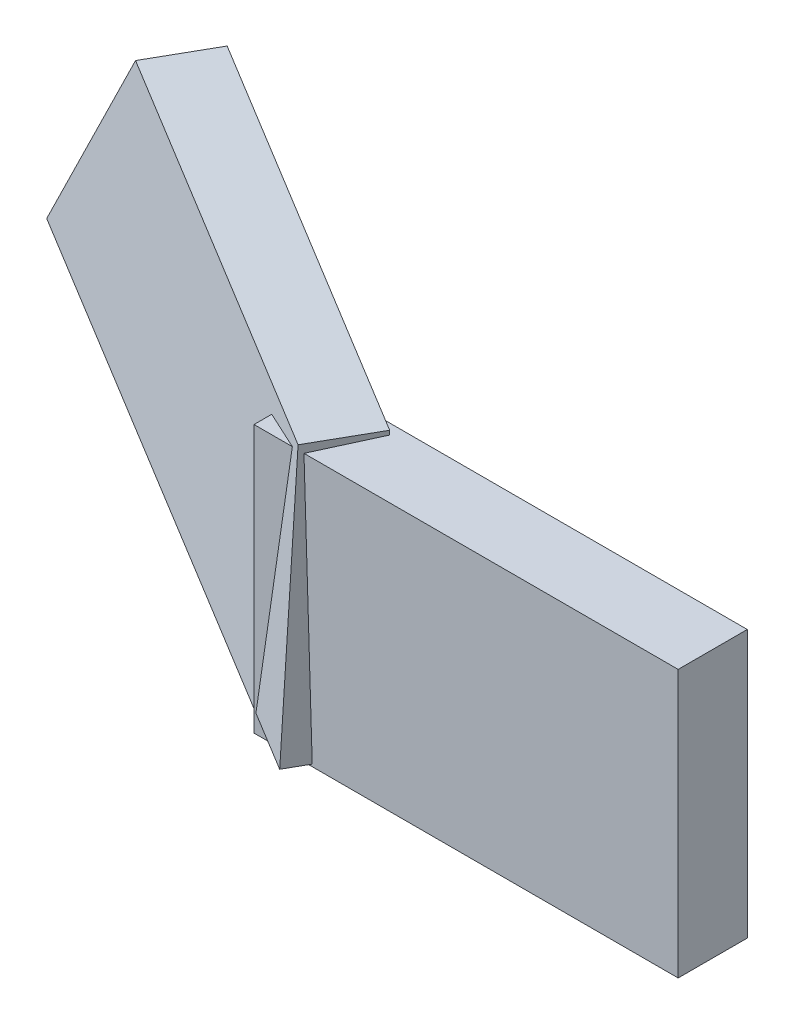
from build123d import *

# Parameters (mm, degrees)
SKETCH1_W           = 61.345012487
SKETCH1_H           = 38.657423861
BOSS_EXTRUDE1_DEPTH = 10
BOSS_EXTRUDE2_DEPTH = 10
SKETCH3_W           = 55.653219253
SKETCH3_H           = 4.667772156
BOSS_EXTRUDE3_DEPTH = 3
BOSS_EXTRUDE4_DEPTH = 3


with BuildPart() as part:
    # Sketch1 → Boss-Extrude1 (new body)
    with BuildSketch(Plane.XY):
        with Locations((-23.425520154, 10.330558338)):
            Rectangle(SKETCH1_W, SKETCH1_H)
    extrude(amount=BOSS_EXTRUDE1_DEPTH)

    # Sketch2 → Boss-Extrude2 (add)
    with BuildSketch(Plane(origin=(-8.887322321, 1.300253896, 19.221447103), x_dir=(0.908038086, 0.028271458, 0.417932481), z_dir=(-0.418887615, 0.061285079, 0.905967607))):
        Polygon((-87.68448092, 45.888055238), (-37.545380932, 30.082102221), (-37.545380932, -9.327101998), (-109.421725422, 13.33134469), align=None)
    extrude(amount=BOSS_EXTRUDE2_DEPTH)

    # Sketch3 → Boss-Extrude3 (add)
    with BuildSketch(Plane.XZ):
        with Locations((-25.061108276, -1.221803115)):
            Rectangle(SKETCH3_W, SKETCH3_H)
    extrude(amount=BOSS_EXTRUDE3_DEPTH)

    # Sketch5 → Boss-Extrude4 (add)
    with BuildSketch(Plane(origin=(-3.775073918, -13.275413408, -0.84743311), x_dir=(0.962011868, -0.272453087, -0.017391983), z_dir=(-0.27300763, -0.960057797, -0.061285079))):
        Polygon((-47.103632436, 2.289571082), (-100.846305257, -21.775814591), (-98.638237359, -26.887445035), (-46.85648275, -2.542586037), (-46.85648275, 2.289571082), align=None)
    extrude(amount=BOSS_EXTRUDE4_DEPTH)


solid = part.part
